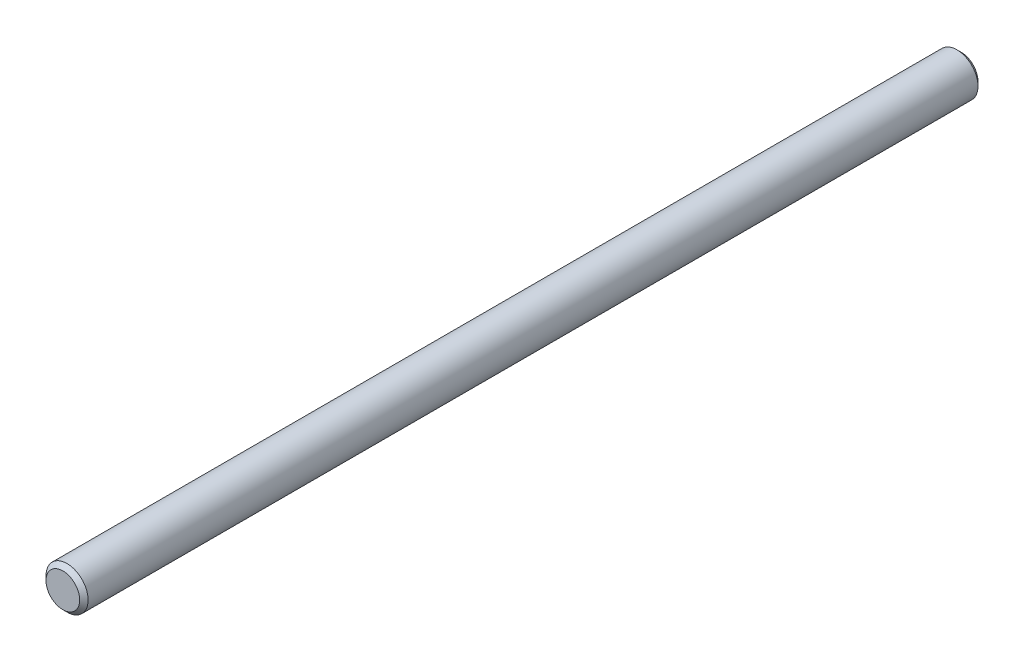
from build123d import *

# Parameters (mm, degrees)
SKETCH1_R      = 2.38125
EXTRUDE1_DEPTH = 50.8
CHAMFER1_SIZE  = 0.47625


with BuildPart() as part:
    # Sketch1 → Extrude1 (new body, symmetric)
    with BuildSketch(Plane.XY):
        Circle(SKETCH1_R)
    extrude(amount=EXTRUDE1_DEPTH, both=True)

    # Chamfer1
    chamfer1_edges = [part.edges().sort_by_distance(p)[0] for p in [
        (-2.38125, 0, -50.8),
        (-2.38125, 0, 50.8),
    ]]
    chamfer(chamfer1_edges, length=CHAMFER1_SIZE)


solid = part.part
